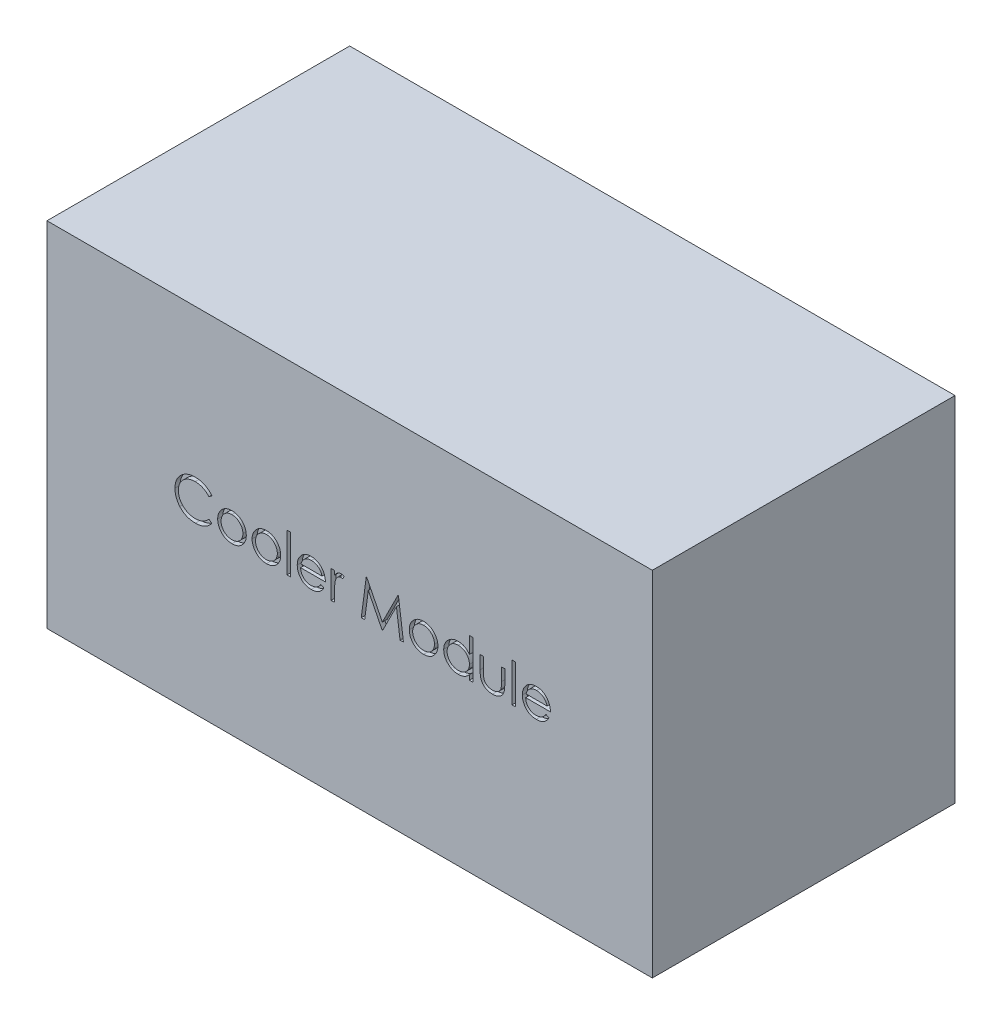
from build123d import *

# Parameters (mm, degrees)
SKETCH1_W           = 304.8
SKETCH1_H           = 177.8
BOSS_EXTRUDE1_DEPTH = 76.2
SKETCH2_W           = 1.709615385
SKETCH2_H           = 19.538461538
CUT_EXTRUDE1_DEPTH  = 2.54


with BuildPart() as part:
    # Sketch1 → Boss-Extrude1 (new body, symmetric)
    with BuildSketch(Plane.XY):
        Rectangle(SKETCH1_W, SKETCH1_H)
    extrude(amount=BOSS_EXTRUDE1_DEPTH, both=True)

    # Sketch2 → Cut-Extrude1 (cut)
    with BuildSketch(Plane.XY.offset(76.2)):
        with BuildLine():
            Line((-69.387672667, 10.444990481), (-70.883586129, 9.30015875))
            add(Edge.make_bspline(
                [(-70.883586129, 9.30015875), (-70.990298178, 9.427336386), (-71.202283568, 9.679977027), (-71.543328656, 10.034739977), (-71.898756169, 10.367109471), (-72.268430243, 10.678668844), (-72.659004879, 10.958522955), (-73.061018655, 11.221255672), (-73.481196587, 11.456755789), (-74.062231028, 11.742304328), (-74.822314316, 12.040279828), (-75.779140512, 12.290124559), (-76.777965205, 12.449171244), (-77.459397855, 12.466397024), (-77.806001994, 12.47515875)],
                knots=[0, 0, 0, 0, 0.00049794, 0.000989166, 0.001475147, 0.001957397, 0.002438287, 0.002915667, 0.003397525, 0.003882215, 0.004857325, 0.005840349, 0.006844209, 0.007883375, 0.007883375, 0.007883375, 0.007883375], degree=3))
            add(Edge.make_bspline(
                [(-77.806001994, 12.47515875), (-77.996955381, 12.47296004), (-78.377089926, 12.468583026), (-78.94123376, 12.410839073), (-79.494843367, 12.329679487), (-80.037558633, 12.209254513), (-80.568688736, 12.057003544), (-81.091705953, 11.875073791), (-81.599037932, 11.649985305), (-82.097702914, 11.401201776), (-82.57547262, 11.12020097), (-83.02752938, 10.81369544), (-83.452224463, 10.485115072), (-83.849893823, 10.133228336), (-84.220943999, 9.759619951), (-84.562686362, 9.360308321), (-84.873938381, 8.936570062), (-85.160869617, 8.493992801), (-85.41784178, 8.033865678), (-85.632997266, 7.554485651), (-85.823525146, 7.064061891), (-85.974288167, 6.55705343), (-86.09362018, 6.037027804), (-86.17595789, 5.502589373), (-86.23304514, 4.954854631), (-86.237400389, 4.583601086), (-86.239595744, 4.396462837)],
                knots=[0, 0, 0, 0, 0.000572619, 0.001139924, 0.001699592, 0.002250514, 0.002806148, 0.003356514, 0.003910218, 0.00446999, 0.005027612, 0.005571644, 0.006107491, 0.006637367, 0.007163561, 0.007685922, 0.008212558, 0.008739692, 0.009267502, 0.009791769, 0.010314798, 0.010844798, 0.0113771, 0.011914141, 0.012466252, 0.013027427, 0.013027427, 0.013027427, 0.013027427], degree=3))
            add(Edge.make_bspline(
                [(-86.239595744, 4.396462837), (-86.232727844, 4.114896653), (-86.219243632, 3.562078798), (-86.099237699, 2.752341618), (-85.916874274, 1.97662195), (-85.643558062, 1.239768809), (-85.306541515, 0.532696174), (-84.880689044, -0.132632442), (-84.387476176, -0.766271172), (-83.819925408, -1.35324493), (-83.197230895, -1.889441064), (-82.529131548, -2.361612086), (-81.817291353, -2.755211661), (-81.06956998, -3.082740741), (-80.28021356, -3.334509501), (-79.450641564, -3.511751374), (-78.582658275, -3.627369528), (-77.989553399, -3.638438601), (-77.687702715, -3.644072019)],
                knots=[0, 0, 0, 0, 0.000844222, 0.001657519, 0.002450727, 0.003230596, 0.004010586, 0.004796148, 0.005595401, 0.006415872, 0.007241219, 0.008057492, 0.008865515, 0.009677279, 0.010502758, 0.011346325, 0.012219621, 0.01312469, 0.01312469, 0.01312469, 0.01312469], degree=3))
            add(Edge.make_bspline(
                [(-77.687702715, -3.644072019), (-77.355129508, -3.634880232), (-76.700545878, -3.616788596), (-75.740599906, -3.463521826), (-74.821650953, -3.215012302), (-73.94364959, -2.867225039), (-73.109071015, -2.415112544), (-72.316609193, -1.867028382), (-71.565595216, -1.217759028), (-71.11399438, -0.722006573), (-70.883586129, -0.469072019)],
                knots=[0, 0, 0, 0, 0.000997238, 0.001962804, 0.002907981, 0.00384834, 0.004789132, 0.005749229, 0.006733947, 0.007759692, 0.007759692, 0.007759692, 0.007759692], degree=3))
            Line((-70.883586129, -0.469072019), (-69.387672667, -1.602455432))
            add(Edge.make_bspline(
                [(-69.387672667, -1.602455432), (-69.50805838, -1.757786149), (-69.748253164, -2.067703558), (-70.137188942, -2.504611006), (-70.546912518, -2.915568685), (-70.980467168, -3.297263309), (-71.432865434, -3.657332615), (-71.912230448, -3.985546868), (-72.412260468, -4.286487253), (-72.931261274, -4.56204237), (-73.468681438, -4.806520529), (-74.023877006, -5.015818894), (-74.594454852, -5.196112935), (-75.180441062, -5.344441334), (-75.78305111, -5.460216805), (-76.400110405, -5.537612463), (-77.032950726, -5.590636312), (-77.459896175, -5.595469111), (-77.676254398, -5.597918173)],
                knots=[0, 0, 0, 0, 0.000589425, 0.001176026, 0.001753482, 0.00232931, 0.002908013, 0.003487018, 0.004070795, 0.004658029, 0.005248935, 0.005840739, 0.006436956, 0.007043188, 0.007653157, 0.008276538, 0.008908147, 0.009557065, 0.009557065, 0.009557065, 0.009557065], degree=3))
            add(Edge.make_bspline(
                [(-77.676254398, -5.597918173), (-77.8811435, -5.596492185), (-78.286286328, -5.59367247), (-78.884449533, -5.547995102), (-79.466778537, -5.485675819), (-80.031609001, -5.391840249), (-80.582023236, -5.281108912), (-81.113031561, -5.132675358), (-81.629859205, -4.966400609), (-82.130429746, -4.770974895), (-82.615168969, -4.550451102), (-83.082513428, -4.301214188), (-83.532248181, -4.025360039), (-83.968794829, -3.728969197), (-84.385704534, -3.402521311), (-84.786590151, -3.050550057), (-85.173699629, -2.674241742), (-85.413199957, -2.402888897), (-85.533616177, -2.266457836)],
                knots=[0, 0, 0, 0, 0.0006145, 0.001215097, 0.001798762, 0.002370923, 0.002932241, 0.003482144, 0.004023991, 0.004560449, 0.005093244, 0.005620764, 0.006148271, 0.006675391, 0.00720287, 0.00773561, 0.008275316, 0.008821059, 0.008821059, 0.008821059, 0.008821059], degree=3))
            add(Edge.make_bspline(
                [(-85.533616177, -2.266457836), (-85.726487322, -2.029469365), (-86.109901103, -1.558353556), (-86.600442324, -0.794797001), (-87.020345446, 0.002408536), (-87.359848672, 0.837451292), (-87.625257262, 1.708457499), (-87.809123481, 2.615866228), (-87.928602928, 3.558830027), (-87.942266072, 4.200198834), (-87.949211129, 4.526210433)],
                knots=[0, 0, 0, 0, 0.000916064, 0.001821069, 0.002717204, 0.003615773, 0.004521164, 0.005444709, 0.006390426, 0.007368094, 0.007368094, 0.007368094, 0.007368094], degree=3))
            add(Edge.make_bspline(
                [(-87.949211129, 4.526210433), (-87.940746433, 4.868867973), (-87.924092671, 5.543025291), (-87.78260127, 6.532394951), (-87.554987536, 7.480276136), (-87.231698757, 8.384899375), (-86.821822488, 9.251022757), (-86.315491918, 10.072029886), (-85.71858933, 10.853171324), (-85.03579614, 11.582594471), (-84.287036786, 12.249558661), (-83.485201528, 12.836332428), (-82.631859788, 13.32465205), (-81.736412624, 13.732845449), (-80.792154843, 14.046596027), (-79.801101076, 14.266232657), (-78.765113555, 14.402941533), (-78.058290924, 14.420223736), (-77.699151033, 14.429004904)],
                knots=[0, 0, 0, 0, 0.001027553, 0.002021647, 0.002991636, 0.003947584, 0.004898354, 0.00586111, 0.006835779, 0.007842891, 0.008853835, 0.009840024, 0.01081793, 0.011798246, 0.012787788, 0.013796915, 0.014839669, 0.015916785, 0.015916785, 0.015916785, 0.015916785], degree=3))
            add(Edge.make_bspline(
                [(-77.699151033, 14.429004904), (-77.480269407, 14.426380695), (-77.047015272, 14.421186337), (-76.406104406, 14.370534335), (-75.782122598, 14.286095992), (-75.174639968, 14.171164241), (-74.580701156, 14.028521534), (-74.00484556, 13.842700767), (-73.443694135, 13.630230504), (-72.900785964, 13.385527997), (-72.378725884, 13.110844733), (-71.877676493, 12.80922541), (-71.401617762, 12.481043955), (-70.947199887, 12.129091528), (-70.52202451, 11.745922227), (-70.114019891, 11.342075312), (-69.737041737, 10.905918355), (-69.504342204, 10.598914357), (-69.387672667, 10.444990481)],
                knots=[0, 0, 0, 0, 0.000656548, 0.00129957, 0.001927235, 0.002544702, 0.003153715, 0.00375836, 0.004358654, 0.004953036, 0.005543646, 0.006127422, 0.006706428, 0.007277417, 0.007850392, 0.008422452, 0.008998633, 0.009577991, 0.009577991, 0.009577991, 0.009577991], degree=3))
        make_face()
        with BuildLine():
            add(Edge.make_bspline(
                [(-59.244463533, 9.055927981), (-58.983253891, 9.050365974), (-58.471085619, 9.039460236), (-57.721016983, 8.922901637), (-57.0050356, 8.744662411), (-56.320399325, 8.498255766), (-55.675876346, 8.167972578), (-55.062078574, 7.773859151), (-54.480688855, 7.306956749), (-54.132220653, 6.945779262), (-53.955340937, 6.762448414)],
                knots=[0, 0, 0, 0, 0.000783055, 0.00153538, 0.002271186, 0.002994326, 0.003712818, 0.004438972, 0.005179778, 0.005943429, 0.005943429, 0.005943429, 0.005943429], degree=3))
            add(Edge.make_bspline(
                [(-53.955340937, 6.762448414), (-53.803039158, 6.587112291), (-53.50138306, 6.239833283), (-53.114582505, 5.676739161), (-52.781362299, 5.093590899), (-52.514319611, 4.482644735), (-52.303762554, 3.849234025), (-52.154270693, 3.19118165), (-52.06535109, 2.509940875), (-52.053360655, 2.047277128), (-52.047288052, 1.812959231)],
                knots=[0, 0, 0, 0, 0.000696259, 0.001379043, 0.002045498, 0.002708457, 0.003375796, 0.004045107, 0.00473002, 0.005432847, 0.005432847, 0.005432847, 0.005432847], degree=3))
            add(Edge.make_bspline(
                [(-52.047288052, 1.812959231), (-52.052629331, 1.577283203), (-52.063183947, 1.11157638), (-52.16302563, 0.425670975), (-52.318316255, -0.239417989), (-52.540558117, -0.880906022), (-52.825535826, -1.500753982), (-53.173283711, -2.096254529), (-53.586242084, -2.668582569), (-54.054349553, -3.212878289), (-54.571703336, -3.714525829), (-55.1329498, -4.151741125), (-55.727059612, -4.52632685), (-56.361932721, -4.828059341), (-57.031771471, -5.065964996), (-57.738020656, -5.233060799), (-58.47958311, -5.334089392), (-58.985916986, -5.347062841), (-59.244463533, -5.353687404)],
                knots=[0, 0, 0, 0, 0.000706639, 0.001396352, 0.002074825, 0.002753062, 0.003429246, 0.004118441, 0.004818465, 0.005543646, 0.006269639, 0.006976516, 0.007674289, 0.008372397, 0.009080888, 0.009802849, 0.01054601, 0.011321441, 0.011321441, 0.011321441, 0.011321441], degree=3))
            add(Edge.make_bspline(
                [(-59.244463533, -5.353687404), (-59.504276792, -5.347040607), (-60.013134185, -5.33402252), (-60.757314173, -5.23345331), (-61.464829099, -5.066042005), (-62.135544756, -4.827277509), (-62.773147423, -4.526317206), (-63.370699642, -4.152873581), (-63.93240204, -3.714396165), (-64.449865269, -3.212913422), (-64.917943393, -2.668573517), (-65.330909338, -2.096256879), (-65.678655256, -1.50075337), (-65.96363348, -0.880906185), (-66.185875205, -0.239417945), (-66.341165866, 0.425670963), (-66.44100754, 1.111576383), (-66.451562157, 1.577283204), (-66.456903437, 1.812959231)],
                knots=[0, 0, 0, 0, 0.000779243, 0.001526186, 0.002248147, 0.002956639, 0.00365819, 0.004359201, 0.005066078, 0.005792071, 0.006517252, 0.007217276, 0.007906471, 0.008582655, 0.009260891, 0.009939365, 0.010629078, 0.011335717, 0.011335717, 0.011335717, 0.011335717], degree=3))
            add(Edge.make_bspline(
                [(-66.456903437, 1.812959231), (-66.450789419, 2.046003574), (-66.438684714, 2.507391321), (-66.349854515, 3.187351466), (-66.2009458, 3.844290112), (-65.990136343, 4.475255917), (-65.720632232, 5.08352479), (-65.392094365, 5.668113942), (-65.001348208, 6.228661827), (-64.700891872, 6.575492005), (-64.548850552, 6.751000096)],
                knots=[0, 0, 0, 0, 0.000699014, 0.001383928, 0.002053239, 0.002716956, 0.003376425, 0.004046203, 0.004725856, 0.005422115, 0.005422115, 0.005422115, 0.005422115], degree=3))
            add(Edge.make_bspline(
                [(-64.548850552, 6.751000096), (-64.372237507, 6.935920837), (-64.024896876, 7.299600012), (-63.440613087, 7.765141322), (-62.828325289, 8.167455953), (-62.17667962, 8.491176497), (-61.492605778, 8.746111857), (-60.77295533, 8.923361304), (-60.020341453, 9.039040279), (-59.505666944, 9.050242647), (-59.244463533, 9.055927981)],
                knots=[0, 0, 0, 0, 0.000766344, 0.00150715, 0.002235377, 0.002960688, 0.003685145, 0.004420951, 0.005180826, 0.005963881, 0.005963881, 0.005963881, 0.005963881], degree=3))
        make_face()
        with BuildLine():
            add(Edge.make_bspline(
                [(-59.252095744, 7.346312596), (-59.436813315, 7.341062462), (-59.801480001, 7.330697724), (-60.338252312, 7.2518639), (-60.854998007, 7.126963913), (-61.352697458, 6.949504693), (-61.829672297, 6.7203664), (-62.286379187, 6.438925182), (-62.724161467, 6.108908662), (-63.134455269, 5.730833264), (-63.511004711, 5.317834736), (-63.840177698, 4.877788669), (-64.120077205, 4.417832698), (-64.35325007, 3.93748852), (-64.526916337, 3.431888382), (-64.653043788, 2.906758089), (-64.73180324, 2.361027751), (-64.742070529, 1.990037065), (-64.747288052, 1.801510914)],
                knots=[0, 0, 0, 0, 0.00055398, 0.001093659, 0.001624001, 0.002146641, 0.00267576, 0.003208513, 0.003753455, 0.004317942, 0.004879857, 0.00542785, 0.00596386, 0.006492979, 0.007026416, 0.007564175, 0.008111411, 0.008676826, 0.008676826, 0.008676826, 0.008676826], degree=3))
            add(Edge.make_bspline(
                [(-64.747288052, 1.801510914), (-64.738542341, 1.557932023), (-64.721183739, 1.074473473), (-64.580021952, 0.36248722), (-64.343876628, -0.321036861), (-64.024994435, -0.972091762), (-63.625454873, -1.574465161), (-63.154718124, -2.111519955), (-62.617836327, -2.575174157), (-62.021209375, -2.959879902), (-61.377023731, -3.265549429), (-60.695271469, -3.482169569), (-59.984212834, -3.622985494), (-59.498270569, -3.636981662), (-59.252095744, -3.644072019)],
                knots=[0, 0, 0, 0, 0.000730313, 0.001449535, 0.002167582, 0.002894618, 0.003618562, 0.004329721, 0.005030483, 0.005739673, 0.006453204, 0.007162815, 0.007881317, 0.008619021, 0.008619021, 0.008619021, 0.008619021], degree=3))
            add(Edge.make_bspline(
                [(-59.252095744, -3.644072019), (-59.005935079, -3.636940351), (-58.520020764, -3.622862635), (-57.809950101, -3.482878774), (-57.130061197, -3.264600278), (-56.486544645, -2.960223678), (-55.890189275, -2.573713249), (-55.349446201, -2.114138111), (-54.88272876, -1.57304272), (-54.483584425, -0.971293885), (-54.159480011, -0.322046197), (-53.924440012, 0.362613374), (-53.782938866, 1.074441345), (-53.76562607, 1.557921259), (-53.756903437, 1.801510914)],
                knots=[0, 0, 0, 0, 0.000737704, 0.001456207, 0.002162186, 0.002875716, 0.003584906, 0.004288562, 0.004997207, 0.005721152, 0.006449878, 0.007167925, 0.007887147, 0.00861746, 0.00861746, 0.00861746, 0.00861746], degree=3))
            add(Edge.make_bspline(
                [(-53.756903437, 1.801510914), (-53.762119164, 1.990038192), (-53.772382918, 2.361031095), (-53.851168081, 2.906745306), (-53.977200375, 3.431935282), (-54.151217321, 3.937315472), (-54.383377025, 4.419076388), (-54.668674141, 4.876438188), (-54.996503008, 5.319359103), (-55.377596195, 5.729498205), (-55.787461723, 6.109056047), (-56.225421431, 6.439053152), (-56.6814511, 6.719129493), (-57.157040243, 6.951464603), (-57.654803504, 7.125349412), (-58.170825164, 7.252585078), (-58.705307258, 7.330364577), (-59.068667193, 7.34096259), (-59.252095744, 7.346312596)],
                knots=[0, 0, 0, 0, 0.000565415, 0.00111265, 0.00165041, 0.002183846, 0.002712966, 0.003250969, 0.003798962, 0.004363449, 0.004927936, 0.005472878, 0.006005632, 0.006531314, 0.007057549, 0.007584185, 0.008123864, 0.008674032, 0.008674032, 0.008674032, 0.008674032], degree=3))
        make_face(mode=Mode.SUBTRACT)
        with BuildLine():
            add(Edge.make_bspline(
                [(-41.904078917, 9.055927981), (-41.642869275, 9.050365974), (-41.130701003, 9.039460236), (-40.380632367, 8.922901637), (-39.664650985, 8.744662411), (-38.98001471, 8.498255766), (-38.335491731, 8.167972578), (-37.721693959, 7.773859151), (-37.140304239, 7.306956749), (-36.791836037, 6.945779262), (-36.614956321, 6.762448414)],
                knots=[0, 0, 0, 0, 0.000783055, 0.00153538, 0.002271186, 0.002994326, 0.003712818, 0.004438972, 0.005179778, 0.005943429, 0.005943429, 0.005943429, 0.005943429], degree=3))
            add(Edge.make_bspline(
                [(-36.614956321, 6.762448414), (-36.462654543, 6.587112291), (-36.160998445, 6.239833283), (-35.774197889, 5.676739161), (-35.440977683, 5.093590899), (-35.173934996, 4.482644735), (-34.963377938, 3.849234025), (-34.813886077, 3.19118165), (-34.724966474, 2.509940875), (-34.71297604, 2.047277128), (-34.706903437, 1.812959231)],
                knots=[0, 0, 0, 0, 0.000696259, 0.001379043, 0.002045498, 0.002708457, 0.003375796, 0.004045107, 0.00473002, 0.005432847, 0.005432847, 0.005432847, 0.005432847], degree=3))
            add(Edge.make_bspline(
                [(-34.706903437, 1.812959231), (-34.712244715, 1.577283203), (-34.722799332, 1.11157638), (-34.822641015, 0.425670975), (-34.97793164, -0.239417989), (-35.200173502, -0.880906022), (-35.485151211, -1.500753982), (-35.832899096, -2.096254529), (-36.245857469, -2.668582569), (-36.713964937, -3.212878289), (-37.23131872, -3.714525829), (-37.792565185, -4.151741125), (-38.386674997, -4.52632685), (-39.021548105, -4.828059341), (-39.691386855, -5.065964996), (-40.39763604, -5.233060799), (-41.139198494, -5.334089392), (-41.645532371, -5.347062841), (-41.904078917, -5.353687404)],
                knots=[0, 0, 0, 0, 0.000706639, 0.001396352, 0.002074825, 0.002753062, 0.003429246, 0.004118441, 0.004818465, 0.005543646, 0.006269639, 0.006976516, 0.007674289, 0.008372397, 0.009080888, 0.009802849, 0.01054601, 0.011321441, 0.011321441, 0.011321441, 0.011321441], degree=3))
            add(Edge.make_bspline(
                [(-41.904078917, -5.353687404), (-42.163892176, -5.347040607), (-42.67274957, -5.33402252), (-43.416929557, -5.23345331), (-44.124444483, -5.066042005), (-44.795160141, -4.827277509), (-45.432762808, -4.526317206), (-46.030315027, -4.152873581), (-46.592017424, -3.714396165), (-47.109480654, -3.212913422), (-47.577558777, -2.668573517), (-47.990524723, -2.096256879), (-48.338270641, -1.50075337), (-48.623248865, -0.880906185), (-48.845490589, -0.239417945), (-49.000781251, 0.425670963), (-49.100622924, 1.111576383), (-49.111177542, 1.577283204), (-49.116518821, 1.812959231)],
                knots=[0, 0, 0, 0, 0.000779243, 0.001526186, 0.002248147, 0.002956639, 0.00365819, 0.004359201, 0.005066078, 0.005792071, 0.006517252, 0.007217276, 0.007906471, 0.008582655, 0.009260891, 0.009939365, 0.010629078, 0.011335717, 0.011335717, 0.011335717, 0.011335717], degree=3))
            add(Edge.make_bspline(
                [(-49.116518821, 1.812959231), (-49.110404803, 2.046003574), (-49.098300099, 2.507391321), (-49.0094699, 3.187351466), (-48.860561185, 3.844290112), (-48.649751727, 4.475255917), (-48.380247617, 5.08352479), (-48.05170975, 5.668113942), (-47.660963592, 6.228661827), (-47.360507256, 6.575492005), (-47.208465937, 6.751000096)],
                knots=[0, 0, 0, 0, 0.000699014, 0.001383928, 0.002053239, 0.002716956, 0.003376425, 0.004046203, 0.004725856, 0.005422115, 0.005422115, 0.005422115, 0.005422115], degree=3))
            add(Edge.make_bspline(
                [(-47.208465937, 6.751000096), (-47.031852891, 6.935920837), (-46.684512261, 7.299600012), (-46.100228471, 7.765141322), (-45.487940674, 8.167455953), (-44.836295004, 8.491176497), (-44.152221163, 8.746111857), (-43.432570714, 8.923361304), (-42.679956837, 9.039040279), (-42.165282328, 9.050242647), (-41.904078917, 9.055927981)],
                knots=[0, 0, 0, 0, 0.000766344, 0.00150715, 0.002235377, 0.002960688, 0.003685145, 0.004420951, 0.005180826, 0.005963881, 0.005963881, 0.005963881, 0.005963881], degree=3))
        make_face()
        with BuildLine():
            add(Edge.make_bspline(
                [(-41.911711129, 7.346312596), (-42.096428699, 7.341062462), (-42.461095385, 7.330697724), (-42.997867696, 7.2518639), (-43.514613391, 7.126963913), (-44.012312843, 6.949504693), (-44.489287681, 6.7203664), (-44.945994572, 6.438925182), (-45.383776852, 6.108908662), (-45.794070654, 5.730833264), (-46.170620095, 5.317834736), (-46.499793082, 4.877788669), (-46.77969259, 4.417832698), (-47.012865455, 3.93748852), (-47.186531722, 3.431888382), (-47.312659173, 2.906758089), (-47.391418624, 2.361027751), (-47.401685913, 1.990037065), (-47.406903437, 1.801510914)],
                knots=[0, 0, 0, 0, 0.00055398, 0.001093659, 0.001624001, 0.002146641, 0.00267576, 0.003208513, 0.003753455, 0.004317942, 0.004879857, 0.00542785, 0.00596386, 0.006492979, 0.007026416, 0.007564175, 0.008111411, 0.008676826, 0.008676826, 0.008676826, 0.008676826], degree=3))
            add(Edge.make_bspline(
                [(-47.406903437, 1.801510914), (-47.398157725, 1.557932023), (-47.380799123, 1.074473473), (-47.239637336, 0.36248722), (-47.003492013, -0.321036861), (-46.684609819, -0.972091762), (-46.285070257, -1.574465161), (-45.814333509, -2.111519955), (-45.277451711, -2.575174157), (-44.68082476, -2.959879902), (-44.036639115, -3.265549429), (-43.354886853, -3.482169569), (-42.643828219, -3.622985494), (-42.157885953, -3.636981662), (-41.911711129, -3.644072019)],
                knots=[0, 0, 0, 0, 0.000730313, 0.001449535, 0.002167582, 0.002894618, 0.003618562, 0.004329721, 0.005030483, 0.005739673, 0.006453204, 0.007162815, 0.007881317, 0.008619021, 0.008619021, 0.008619021, 0.008619021], degree=3))
            add(Edge.make_bspline(
                [(-41.911711129, -3.644072019), (-41.665550464, -3.636940351), (-41.179636149, -3.622862635), (-40.469565486, -3.482878774), (-39.789676582, -3.264600278), (-39.14616003, -2.960223678), (-38.54980466, -2.573713249), (-38.009061585, -2.114138111), (-37.542344145, -1.57304272), (-37.143199809, -0.971293885), (-36.819095395, -0.322046197), (-36.584055397, 0.362613374), (-36.442554251, 1.074441345), (-36.425241455, 1.557921259), (-36.416518821, 1.801510914)],
                knots=[0, 0, 0, 0, 0.000737704, 0.001456207, 0.002162186, 0.002875716, 0.003584906, 0.004288562, 0.004997207, 0.005721152, 0.006449878, 0.007167925, 0.007887147, 0.00861746, 0.00861746, 0.00861746, 0.00861746], degree=3))
            add(Edge.make_bspline(
                [(-36.416518821, 1.801510914), (-36.421734548, 1.990038192), (-36.431998302, 2.361031095), (-36.510783466, 2.906745306), (-36.63681576, 3.431935282), (-36.810832705, 3.937315472), (-37.042992409, 4.419076388), (-37.328289526, 4.876438188), (-37.656118393, 5.319359103), (-38.037211579, 5.729498205), (-38.447077108, 6.109056047), (-38.885036815, 6.439053152), (-39.341066485, 6.719129493), (-39.816655627, 6.951464603), (-40.314418888, 7.125349412), (-40.830440549, 7.252585078), (-41.364922643, 7.330364577), (-41.728282578, 7.34096259), (-41.911711129, 7.346312596)],
                knots=[0, 0, 0, 0, 0.000565415, 0.00111265, 0.00165041, 0.002183846, 0.002712966, 0.003250969, 0.003798962, 0.004363449, 0.004927936, 0.005472878, 0.006005632, 0.006531314, 0.007057549, 0.007584185, 0.008123864, 0.008674032, 0.008674032, 0.008674032, 0.008674032], degree=3))
        make_face(mode=Mode.SUBTRACT)
        with Locations((-30.677095745, 4.659774135)):
            Rectangle(SKETCH2_W, SKETCH2_H)
        with BuildLine():
            Line((-14.489175071, -0.713302788), (-12.970364975, -1.510868894))
            add(Edge.make_bspline(
                [(-12.970364975, -1.510868894), (-13.091395586, -1.725553311), (-13.326873227, -2.143244171), (-13.731825869, -2.717094726), (-14.156325578, -3.233337293), (-14.619534318, -3.678180126), (-15.107593571, -4.065991236), (-15.623209878, -4.40528711), (-16.169067586, -4.694403628), (-16.745192516, -4.937985244), (-17.35642293, -5.125271205), (-18.004240041, -5.257555607), (-18.689884894, -5.339325112), (-19.159854816, -5.348823664), (-19.400503196, -5.353687404)],
                knots=[0, 0, 0, 0, 0.000738917, 0.001437639, 0.002104094, 0.002741006, 0.003360227, 0.003971996, 0.004589981, 0.005210834, 0.005845755, 0.006504362, 0.00719213, 0.007913868, 0.007913868, 0.007913868, 0.007913868], degree=3))
            add(Edge.make_bspline(
                [(-19.400503196, -5.353687404), (-19.66797596, -5.347443492), (-20.189737834, -5.33526343), (-20.949232743, -5.230257302), (-21.664312149, -5.05895775), (-22.334935849, -4.819659588), (-22.959461538, -4.507090867), (-23.539130476, -4.126311402), (-24.076991038, -3.679277273), (-24.556094234, -3.162116344), (-24.987407367, -2.608675977), (-25.368003616, -2.031973234), (-25.686179062, -1.433459112), (-25.945001126, -0.816943832), (-26.15403332, -0.186313211), (-26.299720664, 0.464170634), (-26.383702578, 1.132747171), (-26.396571918, 1.585034098), (-26.403057283, 1.812959231)],
                knots=[0, 0, 0, 0, 0.000802118, 0.0015647, 0.002294973, 0.003004748, 0.003695927, 0.004384964, 0.005081223, 0.005788532, 0.006495408, 0.007184445, 0.007858774, 0.008525719, 0.00918824, 0.009849264, 0.010522339, 0.011206103, 0.011206103, 0.011206103, 0.011206103], degree=3))
            add(Edge.make_bspline(
                [(-26.403057283, 1.812959231), (-26.397292528, 2.026835379), (-26.385867545, 2.450709662), (-26.313854259, 3.078083554), (-26.18622855, 3.687838417), (-26.011097415, 4.280480912), (-25.784939918, 4.855018756), (-25.508267411, 5.411801616), (-25.180648897, 5.950237021), (-24.927704773, 6.289888363), (-24.80029286, 6.460976058)],
                knots=[0, 0, 0, 0, 0.000641662, 0.001271689, 0.001891381, 0.002508376, 0.003123479, 0.003741276, 0.004371535, 0.00501123, 0.00501123, 0.00501123, 0.00501123], degree=3))
            add(Edge.make_bspline(
                [(-24.80029286, 6.460976058), (-24.627712472, 6.667090908), (-24.288018606, 7.072791413), (-23.713490443, 7.605855729), (-23.091370803, 8.052408276), (-22.429456095, 8.422561403), (-21.720053286, 8.703813682), (-20.972698431, 8.913404951), (-20.17888174, 9.030850982), (-19.636200466, 9.047439905), (-19.358526033, 9.055927981)],
                knots=[0, 0, 0, 0, 0.00080593, 0.001586331, 0.002343585, 0.003098605, 0.003855427, 0.004627573, 0.005422542, 0.006255512, 0.006255512, 0.006255512, 0.006255512], degree=3))
            add(Edge.make_bspline(
                [(-19.358526033, 9.055927981), (-19.07306121, 9.048558086), (-18.5130443, 9.034100033), (-17.696440898, 8.900062418), (-16.923768998, 8.687504943), (-16.195337796, 8.38731074), (-15.51107344, 7.999999465), (-14.875423655, 7.520256014), (-14.277517566, 6.962808996), (-13.929672301, 6.534112099), (-13.752666658, 6.315964039)],
                knots=[0, 0, 0, 0, 0.000855838, 0.001678959, 0.002475209, 0.00325546, 0.004036458, 0.004827156, 0.005639736, 0.006481644, 0.006481644, 0.006481644, 0.006481644], degree=3))
            add(Edge.make_bspline(
                [(-13.752666658, 6.315964039), (-13.632232894, 6.15157026), (-13.392167008, 5.823876957), (-13.091464935, 5.289545373), (-12.830439685, 4.730506281), (-12.621798855, 4.137723093), (-12.452855284, 3.518219378), (-12.330626028, 2.867566384), (-12.258945675, 2.185957867), (-12.244855765, 1.721537615), (-12.237672667, 1.484774135)],
                knots=[0, 0, 0, 0, 0.000610875, 0.001217684, 0.001835763, 0.002459799, 0.003100405, 0.003760536, 0.004443661, 0.005154113, 0.005154113, 0.005154113, 0.005154113], degree=3))
            Line((-12.237672667, 1.484774135), (-24.693441898, 1.484774135))
            add(Edge.make_bspline(
                [(-24.693441898, 1.484774135), (-24.68506204, 1.301347322), (-24.668583388, 0.940645893), (-24.59175668, 0.412847774), (-24.470659783, -0.089927131), (-24.300466742, -0.563907688), (-24.094362913, -1.015284525), (-23.841892083, -1.440709326), (-23.540686796, -1.838244346), (-23.204722632, -2.21144548), (-22.830759728, -2.54379048), (-22.437335061, -2.841252291), (-22.018814371, -3.09056561), (-21.57849766, -3.292930439), (-21.117096943, -3.451351959), (-20.634466853, -3.559489669), (-20.131557105, -3.63191835), (-19.788734753, -3.639971957), (-19.614205119, -3.644072019)],
                knots=[0, 0, 0, 0, 0.000550591, 0.001082716, 0.001597325, 0.002099429, 0.002591174, 0.003083984, 0.003580077, 0.004085261, 0.004587887, 0.005078639, 0.005562939, 0.006046155, 0.006530079, 0.007023479, 0.007528086, 0.008051394, 0.008051394, 0.008051394, 0.008051394], degree=3))
            add(Edge.make_bspline(
                [(-19.614205119, -3.644072019), (-19.443565302, -3.640762453), (-19.10498317, -3.634195641), (-18.600752218, -3.570340525), (-18.10469279, -3.467088025), (-17.618858009, -3.326172508), (-17.15310812, -3.154304213), (-16.721785911, -2.946915802), (-16.325109309, -2.717500752), (-15.954358391, -2.455102378), (-15.594743413, -2.133929245), (-15.238005023, -1.733140535), (-14.855499238, -1.259135563), (-14.616070169, -0.902379867), (-14.489175071, -0.713302788)],
                knots=[0, 0, 0, 0, 0.000511714, 0.001015339, 0.001522019, 0.002030479, 0.002531611, 0.003009539, 0.003464424, 0.003904933, 0.00436984, 0.00490737, 0.005512881, 0.006195665, 0.006195665, 0.006195665, 0.006195665], degree=3))
        make_face()
        with BuildLine():
            add(Edge.make_bspline(
                [(-13.947288052, 3.19438952), (-14.009862537, 3.421154589), (-14.130298278, 3.857604353), (-14.381956205, 4.461984056), (-14.665374162, 4.999128203), (-15.000772443, 5.46492592), (-15.380785792, 5.878602184), (-15.819726, 6.240109055), (-16.311955649, 6.563509753), (-16.854930401, 6.836482643), (-17.429923545, 7.068837445), (-18.031937247, 7.224639861), (-18.646206064, 7.331371798), (-19.06168268, 7.341311045), (-19.2707556, 7.346312596)],
                knots=[0, 0, 0, 0, 0.000705082, 0.001357055, 0.001959783, 0.002523172, 0.003074068, 0.003640358, 0.004224608, 0.004837304, 0.005460908, 0.006081104, 0.00669969, 0.007326276, 0.007326276, 0.007326276, 0.007326276], degree=3))
            add(Edge.make_bspline(
                [(-19.2707556, 7.346312596), (-19.441386115, 7.342983356), (-19.778686771, 7.336402146), (-20.275625442, 7.273971871), (-20.752853518, 7.170776144), (-21.213892297, 7.029452594), (-21.652700167, 6.841082915), (-22.078303119, 6.62019421), (-22.479879276, 6.350546447), (-22.731019756, 6.145030394), (-22.857895023, 6.041204423)],
                knots=[0, 0, 0, 0, 0.000511714, 0.001011551, 0.001499565, 0.001975126, 0.002455668, 0.002930217, 0.003411788, 0.003903473, 0.003903473, 0.003903473, 0.003903473], degree=3))
            add(Edge.make_bspline(
                [(-22.857895023, 6.041204423), (-22.948754172, 5.95904822), (-23.132630946, 5.792784087), (-23.378324355, 5.506330834), (-23.613567214, 5.197440188), (-23.827654667, 4.854294582), (-24.024019816, 4.480801484), (-24.207770549, 4.080111213), (-24.373159449, 3.649183175), (-24.466211133, 3.34888747), (-24.514084927, 3.19438952)],
                knots=[0, 0, 0, 0, 0.00036714, 0.000743003, 0.001129956, 0.001531229, 0.001954593, 0.002395167, 0.002852989, 0.003338129, 0.003338129, 0.003338129, 0.003338129], degree=3))
            Line((-24.514084927, 3.19438952), (-13.947288052, 3.19438952))
        make_face(mode=Mode.SUBTRACT)
        with BuildLine():
            Line((-9.306903437, 8.811697212), (-7.597288052, 8.811697212))
            Line((-7.597288052, 8.811697212), (-7.597288052, 6.762448414))
            add(Edge.make_bspline(
                [(-7.597288052, 6.762448414), (-7.471074951, 6.953252279), (-7.229693375, 7.31816319), (-6.828484431, 7.800777528), (-6.417530585, 8.200365139), (-5.994864495, 8.518791434), (-5.557377979, 8.757259981), (-5.114672571, 8.931937786), (-4.659783228, 9.035228601), (-4.354101897, 9.049018945), (-4.200953917, 9.055927981)],
                knots=[0, 0, 0, 0, 0.000685923, 0.001311823, 0.001878588, 0.00240216, 0.002894023, 0.003368834, 0.003826209, 0.004285428, 0.004285428, 0.004285428, 0.004285428], degree=3))
            add(Edge.make_bspline(
                [(-4.200953917, 9.055927981), (-4.08215634, 9.049448115), (-3.837722605, 9.036115369), (-3.467703081, 8.942439309), (-3.086466578, 8.792880358), (-2.840763013, 8.652235717), (-2.712672667, 8.57891476)],
                knots=[0, 0, 0, 0, 0.000356208, 0.000732922, 0.001138974, 0.001581198, 0.001581198, 0.001581198, 0.001581198], degree=3))
            Line((-2.712672667, 8.57891476), (-3.651434687, 7.098265721))
            add(Edge.make_bspline(
                [(-3.651434687, 7.098265721), (-3.73367093, 7.134952027), (-3.889771064, 7.204589658), (-4.118123774, 7.287005456), (-4.328660764, 7.335533512), (-4.462792132, 7.342885274), (-4.525322908, 7.346312596)],
                knots=[0, 0, 0, 0, 0.000270082, 0.000512668, 0.000727491, 0.000915102, 0.000915102, 0.000915102, 0.000915102], degree=3))
            add(Edge.make_bspline(
                [(-4.525322908, 7.346312596), (-4.662514114, 7.337168393), (-4.942344408, 7.318516869), (-5.353195755, 7.171892786), (-5.751869831, 6.934991122), (-6.068489879, 6.672258357), (-6.313648427, 6.418905345), (-6.488583083, 6.197661896), (-6.649053462, 5.949583916), (-6.802379948, 5.678912351), (-6.942077921, 5.381025618), (-7.072459763, 5.058899842), (-7.19034586, 4.712161927), (-7.257566475, 4.47059421), (-7.29199959, 4.346853462)],
                knots=[0, 0, 0, 0, 0.000410883, 0.000838083, 0.001292968, 0.001797214, 0.002067108, 0.002349602, 0.002641728, 0.002952711, 0.003282158, 0.003627974, 0.003994837, 0.004380112, 0.004380112, 0.004380112, 0.004380112], degree=3))
            add(Edge.make_bspline(
                [(-7.29199959, 4.346853462), (-7.317757332, 4.236487703), (-7.374808771, 3.992035933), (-7.430279855, 3.581924677), (-7.485086803, 3.09738162), (-7.523712683, 2.537058022), (-7.559516026, 1.902353148), (-7.579709474, 1.192300073), (-7.596599425, 0.406169976), (-7.597051546, -0.143419004), (-7.597288052, -0.430910961)],
                knots=[0, 0, 0, 0, 0.000339826, 0.000752689, 0.001240271, 0.001802807, 0.002437211, 0.003147375, 0.003933641, 0.00479609, 0.00479609, 0.00479609, 0.00479609], degree=3))
            Line((-7.597288052, -0.430910961), (-7.597288052, -5.109456634))
            Line((-7.597288052, -5.109456634), (-9.306903437, -5.109456634))
            Line((-9.306903437, -5.109456634), (-9.306903437, 8.811697212))
        make_face()
        Polygon((5.835404256, -5.109456634), (8.350217958, 13.940543366), (8.594448727, 13.940543366), (16.459442717, -1.690225865), (24.305356179, 13.940543366), (24.553403054, 13.940543366), (27.083481179, -5.109456634), (25.366233583, -5.109456634), (23.542135025, 8.597995289), (16.665512429, -5.109456634), (16.280085746, -5.109456634), (9.37675041, 8.628524135), (7.556467958, -5.109456634), align=None)
        with BuildLine():
            add(Edge.make_bspline(
                [(37.226690313, 9.055927981), (37.487899956, 9.050365974), (38.000068227, 9.039460236), (38.750136863, 8.922901637), (39.466118246, 8.744662411), (40.150754521, 8.498255766), (40.7952775, 8.167972578), (41.409075272, 7.773859151), (41.990464992, 7.306956749), (42.338933194, 6.945779262), (42.51581291, 6.762448414)],
                knots=[0, 0, 0, 0, 0.000783055, 0.00153538, 0.002271186, 0.002994326, 0.003712818, 0.004438972, 0.005179778, 0.005943429, 0.005943429, 0.005943429, 0.005943429], degree=3))
            add(Edge.make_bspline(
                [(42.51581291, 6.762448414), (42.668114688, 6.587112291), (42.969770786, 6.239833283), (43.356571341, 5.676739161), (43.689791547, 5.093590899), (43.956834235, 4.482644735), (44.167391292, 3.849234025), (44.316883154, 3.19118165), (44.405802757, 2.509940875), (44.417793191, 2.047277128), (44.423865794, 1.812959231)],
                knots=[0, 0, 0, 0, 0.000696259, 0.001379043, 0.002045498, 0.002708457, 0.003375796, 0.004045107, 0.00473002, 0.005432847, 0.005432847, 0.005432847, 0.005432847], degree=3))
            add(Edge.make_bspline(
                [(44.423865794, 1.812959231), (44.418524515, 1.577283203), (44.407969899, 1.11157638), (44.308128216, 0.425670975), (44.152837591, -0.239417989), (43.930595729, -0.880906022), (43.64561802, -1.500753982), (43.297870135, -2.096254529), (42.884911762, -2.668582569), (42.416804294, -3.212878289), (41.899450511, -3.714525829), (41.338204046, -4.151741125), (40.744094234, -4.52632685), (40.109221125, -4.828059341), (39.439382376, -5.065964996), (38.733133191, -5.233060799), (37.991570737, -5.334089392), (37.48523686, -5.347062841), (37.226690313, -5.353687404)],
                knots=[0, 0, 0, 0, 0.000706639, 0.001396352, 0.002074825, 0.002753062, 0.003429246, 0.004118441, 0.004818465, 0.005543646, 0.006269639, 0.006976516, 0.007674289, 0.008372397, 0.009080888, 0.009802849, 0.01054601, 0.011321441, 0.011321441, 0.011321441, 0.011321441], degree=3))
            add(Edge.make_bspline(
                [(37.226690313, -5.353687404), (36.966877054, -5.347040607), (36.458019661, -5.33402252), (35.713839673, -5.23345331), (35.006324747, -5.066042005), (34.33560909, -4.827277509), (33.698006423, -4.526317206), (33.100454204, -4.152873581), (32.538751806, -3.714396165), (32.021288577, -3.212913422), (31.553210454, -2.668573517), (31.140244508, -2.096256879), (30.79249859, -1.50075337), (30.507520366, -0.880906185), (30.285278642, -0.239417945), (30.12998798, 0.425670963), (30.030146306, 1.111576383), (30.019591689, 1.577283204), (30.01425041, 1.812959231)],
                knots=[0, 0, 0, 0, 0.000779243, 0.001526186, 0.002248147, 0.002956639, 0.00365819, 0.004359201, 0.005066078, 0.005792071, 0.006517252, 0.007217276, 0.007906471, 0.008582655, 0.009260891, 0.009939365, 0.010629078, 0.011335717, 0.011335717, 0.011335717, 0.011335717], degree=3))
            add(Edge.make_bspline(
                [(30.01425041, 1.812959231), (30.020364427, 2.046003574), (30.032469132, 2.507391321), (30.121299331, 3.187351466), (30.270208046, 3.844290112), (30.481017504, 4.475255917), (30.750521614, 5.08352479), (31.079059481, 5.668113942), (31.469805638, 6.228661827), (31.770261975, 6.575492005), (31.922303294, 6.751000096)],
                knots=[0, 0, 0, 0, 0.000699014, 0.001383928, 0.002053239, 0.002716956, 0.003376425, 0.004046203, 0.004725856, 0.005422115, 0.005422115, 0.005422115, 0.005422115], degree=3))
            add(Edge.make_bspline(
                [(31.922303294, 6.751000096), (32.09891634, 6.935920837), (32.44625697, 7.299600012), (33.030540759, 7.765141322), (33.642828557, 8.167455953), (34.294474227, 8.491176497), (34.978548068, 8.746111857), (35.698198516, 8.923361304), (36.450812393, 9.039040279), (36.965486902, 9.050242647), (37.226690313, 9.055927981)],
                knots=[0, 0, 0, 0, 0.000766344, 0.00150715, 0.002235377, 0.002960688, 0.003685145, 0.004420951, 0.005180826, 0.005963881, 0.005963881, 0.005963881, 0.005963881], degree=3))
        make_face()
        with BuildLine():
            add(Edge.make_bspline(
                [(37.219058102, 7.346312596), (37.034340532, 7.341062462), (36.669673846, 7.330697724), (36.132901535, 7.2518639), (35.61615584, 7.126963913), (35.118456388, 6.949504693), (34.641481549, 6.7203664), (34.184774659, 6.438925182), (33.746992379, 6.108908662), (33.336698577, 5.730833264), (32.960149135, 5.317834736), (32.630976148, 4.877788669), (32.351076641, 4.417832698), (32.117903776, 3.93748852), (31.944237509, 3.431888382), (31.818110058, 2.906758089), (31.739350607, 2.361027751), (31.729083317, 1.990037065), (31.723865794, 1.801510914)],
                knots=[0, 0, 0, 0, 0.00055398, 0.001093659, 0.001624001, 0.002146641, 0.00267576, 0.003208513, 0.003753455, 0.004317942, 0.004879857, 0.00542785, 0.00596386, 0.006492979, 0.007026416, 0.007564175, 0.008111411, 0.008676826, 0.008676826, 0.008676826, 0.008676826], degree=3))
            add(Edge.make_bspline(
                [(31.723865794, 1.801510914), (31.732611506, 1.557932023), (31.749970108, 1.074473473), (31.891131894, 0.36248722), (32.127277218, -0.321036861), (32.446159412, -0.972091762), (32.845698973, -1.574465161), (33.316435722, -2.111519955), (33.85331752, -2.575174157), (34.449944471, -2.959879902), (35.094130115, -3.265549429), (35.775882377, -3.482169569), (36.486941012, -3.622985494), (36.972883277, -3.636981662), (37.219058102, -3.644072019)],
                knots=[0, 0, 0, 0, 0.000730313, 0.001449535, 0.002167582, 0.002894618, 0.003618562, 0.004329721, 0.005030483, 0.005739673, 0.006453204, 0.007162815, 0.007881317, 0.008619021, 0.008619021, 0.008619021, 0.008619021], degree=3))
            add(Edge.make_bspline(
                [(37.219058102, -3.644072019), (37.465218767, -3.636940351), (37.951133082, -3.622862635), (38.661203745, -3.482878774), (39.341092649, -3.264600278), (39.984609201, -2.960223678), (40.580964571, -2.573713249), (41.121707646, -2.114138111), (41.588425086, -1.57304272), (41.987569421, -0.971293885), (42.311673835, -0.322046197), (42.546713834, 0.362613374), (42.68821498, 1.074441345), (42.705527776, 1.557921259), (42.71425041, 1.801510914)],
                knots=[0, 0, 0, 0, 0.000737704, 0.001456207, 0.002162186, 0.002875716, 0.003584906, 0.004288562, 0.004997207, 0.005721152, 0.006449878, 0.007167925, 0.007887147, 0.00861746, 0.00861746, 0.00861746, 0.00861746], degree=3))
            add(Edge.make_bspline(
                [(42.71425041, 1.801510914), (42.709034683, 1.990038192), (42.698770928, 2.361031095), (42.619985765, 2.906745306), (42.493953471, 3.431935282), (42.319936525, 3.937315472), (42.087776821, 4.419076388), (41.802479705, 4.876438188), (41.474650838, 5.319359103), (41.093557651, 5.729498205), (40.683692123, 6.109056047), (40.245732415, 6.439053152), (39.789702746, 6.719129493), (39.314113603, 6.951464603), (38.816350342, 7.125349412), (38.300328682, 7.252585078), (37.765846588, 7.330364577), (37.402486653, 7.34096259), (37.219058102, 7.346312596)],
                knots=[0, 0, 0, 0, 0.000565415, 0.00111265, 0.00165041, 0.002183846, 0.002712966, 0.003250969, 0.003798962, 0.004363449, 0.004927936, 0.005472878, 0.006005632, 0.006531314, 0.007057549, 0.007584185, 0.008123864, 0.008674032, 0.008674032, 0.008674032, 0.008674032], degree=3))
        make_face(mode=Mode.SUBTRACT)
        with BuildLine():
            Line((62.008481179, 14.429004904), (62.008481179, -5.109456634))
            Line((62.008481179, -5.109456634), (60.298865794, -5.109456634))
            Line((60.298865794, -5.109456634), (60.298865794, -2.701493894))
            add(Edge.make_bspline(
                [(60.298865794, -2.701493894), (60.106086377, -2.919423684), (59.729874919, -3.344716409), (59.101545406, -3.900335091), (58.435512894, -4.359594241), (57.735009989, -4.730524497), (57.000669265, -5.009155546), (56.234118561, -5.207200212), (55.435045188, -5.334529515), (54.889385943, -5.347244148), (54.612868198, -5.353687404)],
                knots=[0, 0, 0, 0, 0.000872287, 0.001702279, 0.002508878, 0.003294106, 0.004074404, 0.004859307, 0.005666168, 0.006495142, 0.006495142, 0.006495142, 0.006495142], degree=3))
            add(Edge.make_bspline(
                [(54.612868198, -5.353687404), (54.367025478, -5.347012434), (53.882212748, -5.3338491), (53.1690402, -5.231728562), (52.482738099, -5.067731892), (51.822657925, -4.839671337), (51.193070962, -4.537152865), (50.588586722, -4.174978358), (50.012336784, -3.74368184), (49.47310455, -3.250624142), (48.976541805, -2.715074284), (48.540779736, -2.143870664), (48.177452258, -1.539483267), (47.873631533, -0.909564244), (47.639608573, -0.249264468), (47.476466364, 0.439132689), (47.374464789, 1.154813287), (47.361306896, 1.64216412), (47.354635025, 1.889281346)],
                knots=[0, 0, 0, 0, 0.000737309, 0.001454006, 0.002156521, 0.002851681, 0.003544701, 0.004248243, 0.004962619, 0.005700116, 0.006437375, 0.007150997, 0.007851271, 0.008549378, 0.009245804, 0.00994832, 0.010668797, 0.011409917, 0.011409917, 0.011409917, 0.011409917], degree=3))
            add(Edge.make_bspline(
                [(47.354635025, 1.889281346), (47.361454769, 2.131290933), (47.374937036, 2.60973083), (47.475375275, 3.313376315), (47.644272622, 3.99111142), (47.881297336, 4.640754211), (48.185237119, 5.263090769), (48.554959993, 5.858561248), (48.990492657, 6.428806112), (49.49260933, 6.960416646), (50.036540007, 7.451474561), (50.618428957, 7.878243794), (51.223801388, 8.246816928), (51.862047203, 8.538845135), (52.523719588, 8.77511469), (53.214709057, 8.938579845), (53.932140649, 9.034903836), (54.419224613, 9.048852595), (54.666293679, 9.055927981)],
                knots=[0, 0, 0, 0, 0.000725873, 0.001435012, 0.002127317, 0.002817853, 0.003505652, 0.004201409, 0.004917344, 0.005654405, 0.006392178, 0.007112685, 0.007816226, 0.008514532, 0.009214556, 0.009920783, 0.010640744, 0.011381864, 0.011381864, 0.011381864, 0.011381864], degree=3))
            add(Edge.make_bspline(
                [(54.666293679, 9.055927981), (54.950502304, 9.047398501), (55.50837225, 9.03065608), (56.324248489, 8.890739997), (57.095978197, 8.655810619), (57.828004315, 8.334185217), (58.515962735, 7.916169699), (59.164896308, 7.411336818), (59.763519822, 6.805399066), (60.117696457, 6.350313216), (60.298865794, 6.117526539)],
                knots=[0, 0, 0, 0, 0.000852223, 0.001672819, 0.002474401, 0.003267159, 0.004064945, 0.004883275, 0.005727876, 0.006612324, 0.006612324, 0.006612324, 0.006612324], degree=3))
            Line((60.298865794, 6.117526539), (60.298865794, 14.429004904))
            Line((60.298865794, 14.429004904), (62.008481179, 14.429004904))
        make_face()
        with BuildLine():
            add(Edge.make_bspline(
                [(54.689190313, 7.346312596), (54.439285132, 7.33742094), (53.946012052, 7.319870223), (53.221872555, 7.182854485), (52.528923829, 6.954882622), (51.870631625, 6.643105417), (51.257394618, 6.251063293), (50.709333352, 5.77687405), (50.22196522, 5.233475444), (49.812073097, 4.623319672), (49.477933392, 3.969207491), (49.242981404, 3.28545162), (49.088027357, 2.584384528), (49.072196695, 2.10888191), (49.06425041, 1.870200818)],
                knots=[0, 0, 0, 0, 0.000749357, 0.001479112, 0.002201969, 0.002932562, 0.003658716, 0.004378515, 0.005100122, 0.005842077, 0.006577636, 0.007296929, 0.008006437, 0.008721517, 0.008721517, 0.008721517, 0.008721517], degree=3))
            add(Edge.make_bspline(
                [(49.06425041, 1.870200818), (49.074400757, 1.632946091), (49.094661667, 1.159366597), (49.240261875, 0.457343744), (49.484536615, -0.226573257), (49.817868414, -0.886579521), (50.235262757, -1.499358696), (50.719070994, -2.053115649), (51.273971811, -2.529308979), (51.8886201, -2.92793063), (52.545072053, -3.24994378), (53.235411023, -3.474002475), (53.946659853, -3.618661538), (54.430270413, -3.635558762), (54.67392589, -3.644072019)],
                knots=[0, 0, 0, 0, 0.000711527, 0.001420265, 0.002140823, 0.002884914, 0.00363217, 0.004359486, 0.005084667, 0.005818173, 0.006552067, 0.007271299, 0.007990521, 0.008720835, 0.008720835, 0.008720835, 0.008720835], degree=3))
            add(Edge.make_bspline(
                [(54.67392589, -3.644072019), (54.921284712, -3.635037072), (55.413256876, -3.61706746), (56.139544701, -3.479465145), (56.844367284, -3.252123542), (57.518123484, -2.936986867), (58.145772712, -2.546421829), (58.709096875, -2.089183234), (59.185433788, -1.55739876), (59.589253563, -0.972964066), (59.905894045, -0.332274485), (60.136540882, 0.34990161), (60.272905712, 1.073587968), (60.290092783, 1.568147342), (60.298865794, 1.820591443)],
                knots=[0, 0, 0, 0, 0.000741739, 0.001475246, 0.002208991, 0.002958475, 0.003700744, 0.004421938, 0.005127092, 0.005835223, 0.006546884, 0.007263702, 0.007989706, 0.008746681, 0.008746681, 0.008746681, 0.008746681], degree=3))
            add(Edge.make_bspline(
                [(60.298865794, 1.820591443), (60.293642522, 2.012930206), (60.283361468, 2.391513759), (60.20481794, 2.947379247), (60.079877555, 3.479329956), (59.903821972, 3.987925164), (59.672547981, 4.47035289), (59.393613713, 4.930077071), (59.062114051, 5.364706693), (58.683385376, 5.768256836), (58.268829059, 6.136338009), (57.830164488, 6.464891948), (57.362194451, 6.734796554), (56.872788864, 6.958178332), (56.361098601, 7.135937419), (55.822959942, 7.254524724), (55.264092884, 7.335951614), (54.882842212, 7.342822572), (54.689190313, 7.346312596)],
                knots=[0, 0, 0, 0, 0.000576851, 0.001135425, 0.001680607, 0.002214044, 0.002746606, 0.003282616, 0.003824517, 0.004383403, 0.004940215, 0.005485931, 0.006024597, 0.006557392, 0.007098041, 0.007646075, 0.008208429, 0.008788929, 0.008788929, 0.008788929, 0.008788929], degree=3))
        make_face(mode=Mode.SUBTRACT)
        with BuildLine():
            Line((65.671942717, 8.811697212), (67.381558102, 8.811697212))
            Line((67.381558102, 8.811697212), (67.381558102, 2.35484625))
            add(Edge.make_bspline(
                [(67.381558102, 2.35484625), (67.38233047, 2.165311001), (67.383807974, 1.802738948), (67.393827952, 1.28101286), (67.417396033, 0.805216181), (67.446862707, 0.375074057), (67.484756619, -0.009340746), (67.529841767, -0.346685532), (67.580234033, -0.640785877), (67.629561091, -0.817914713), (67.652501611, -0.900291971)],
                knots=[0, 0, 0, 0, 0.000568613, 0.001087729, 0.001565292, 0.001997591, 0.002381105, 0.002723811, 0.003018715, 0.003275105, 0.003275105, 0.003275105, 0.003275105], degree=3))
            add(Edge.make_bspline(
                [(67.652501611, -0.900291971), (67.689303245, -1.00383074), (67.762141416, -1.208755733), (67.89425852, -1.504787318), (68.057698466, -1.778972784), (68.236549815, -2.041884951), (68.442830876, -2.285735765), (68.673931712, -2.510113434), (68.922116402, -2.723495702), (69.290897315, -2.975961499), (69.795228463, -3.246554938), (70.457367031, -3.48003075), (71.175302889, -3.619562856), (71.671499433, -3.635751301), (71.926540073, -3.644072019)],
                knots=[0, 0, 0, 0, 0.000329624, 0.000652395, 0.000970486, 0.001285932, 0.001605484, 0.001926604, 0.002251534, 0.002586048, 0.00326554, 0.003961966, 0.004684934, 0.005449528, 0.005449528, 0.005449528, 0.005449528], degree=3))
            add(Edge.make_bspline(
                [(71.926540073, -3.644072019), (72.181557022, -3.635574366), (72.674967634, -3.619132979), (73.385015395, -3.484239719), (74.034083808, -3.258874469), (74.615658272, -2.944236985), (75.127100916, -2.559198043), (75.553300681, -2.107392956), (75.904948738, -1.603115578), (76.058488584, -1.226882004), (76.135704736, -1.037671779)],
                knots=[0, 0, 0, 0, 0.000764594, 0.001479347, 0.002158839, 0.002817911, 0.003455212, 0.004070659, 0.004675027, 0.005286462, 0.005286462, 0.005286462, 0.005286462], degree=3))
            add(Edge.make_bspline(
                [(76.135704736, -1.037671779), (76.158533332, -0.96165521), (76.20900178, -0.793601143), (76.263225436, -0.508505655), (76.312072148, -0.168519736), (76.353781721, 0.228581371), (76.383527821, 0.68175993), (76.399562623, 1.190874316), (76.417677949, 1.75432629), (76.417952902, 2.148757952), (76.418096563, 2.35484625)],
                knots=[0, 0, 0, 0, 0.000237979, 0.000526114, 0.000869352, 0.001268441, 0.001723582, 0.002231483, 0.002796473, 0.003414694, 0.003414694, 0.003414694, 0.003414694], degree=3))
            Line((76.418096563, 2.35484625), (76.418096563, 8.811697212))
            Line((76.418096563, 8.811697212), (78.127711948, 8.811697212))
            Line((78.127711948, 8.811697212), (78.127711948, 2.034293366))
            add(Edge.make_bspline(
                [(78.127711948, 2.034293366), (78.125307866, 1.804021475), (78.120643619, 1.357262509), (78.090667935, 0.708016131), (78.039235043, 0.102975912), (77.961169858, -0.458178413), (77.8693724, -0.975018421), (77.750956114, -1.44820652), (77.609560278, -1.876284806), (77.450054546, -2.266765049), (77.261612667, -2.620806002), (77.061168455, -2.956825232), (76.829712197, -3.266485351), (76.586034208, -3.565200983), (76.31497091, -3.838114154), (76.021601677, -4.091487187), (75.710055692, -4.32919326), (75.373419343, -4.541961509), (75.016607058, -4.733640679), (74.63917835, -4.903545332), (74.236510346, -5.03799793), (73.813798264, -5.15398884), (73.36897108, -5.244963307), (72.902457627, -5.309115906), (72.414415044, -5.34844235), (72.081804985, -5.351909695), (71.91127565, -5.353687404)],
                knots=[0, 0, 0, 0, 0.00069081, 0.001340266, 0.001949374, 0.002511729, 0.003039415, 0.003523474, 0.003973597, 0.00439102, 0.004787014, 0.00517577, 0.005563513, 0.0059456, 0.00633148, 0.006715601, 0.0071079, 0.007505947, 0.007908885, 0.008322312, 0.0087459, 0.009181003, 0.009636784, 0.010106847, 0.010592993, 0.011104479, 0.011104479, 0.011104479, 0.011104479], degree=3))
            add(Edge.make_bspline(
                [(71.91127565, -5.353687404), (71.742021766, -5.351838426), (71.409422128, -5.348205013), (70.921354355, -5.309333174), (70.45354837, -5.245062988), (70.007667344, -5.153322448), (69.583263838, -5.038809796), (69.178618761, -4.902719124), (68.798470225, -4.733552502), (68.438251032, -4.543174654), (68.100780891, -4.327826512), (67.784504201, -4.091780467), (67.489845047, -3.835388896), (67.216738434, -3.559722566), (66.969017804, -3.261361812), (66.743596206, -2.942706691), (66.537003282, -2.606914581), (66.350025952, -2.247342225), (66.189397682, -1.852343143), (66.047582701, -1.415297515), (65.931591941, -0.931413816), (65.837199363, -0.401105748), (65.761263665, 0.173088692), (65.708543376, 0.794491067), (65.679065783, 1.461587734), (65.674368263, 1.922324993), (65.671942717, 2.160224856)],
                knots=[0, 0, 0, 0, 0.000507671, 0.000997621, 0.001467684, 0.001923465, 0.002362251, 0.002785839, 0.003202756, 0.003609059, 0.004007107, 0.004402456, 0.004791961, 0.00517784, 0.005565302, 0.005953908, 0.006347911, 0.006747291, 0.007168241, 0.007625617, 0.008124491, 0.008659686, 0.00924095, 0.009861464, 0.010529979, 0.011243683, 0.011243683, 0.011243683, 0.011243683], degree=3))
            Line((65.671942717, 2.160224856), (65.671942717, 8.811697212))
        make_face()
        with Locations((82.645981179, 4.659774135)):
            Rectangle(SKETCH2_W, SKETCH2_H)
        with BuildLine():
            Line((98.833901852, -0.713302788), (100.352711948, -1.510868894))
            add(Edge.make_bspline(
                [(100.352711948, -1.510868894), (100.231681337, -1.725553311), (99.996203696, -2.143244171), (99.591251054, -2.717094726), (99.166751345, -3.233337293), (98.703542605, -3.678180126), (98.215483352, -4.065991236), (97.699867045, -4.40528711), (97.154009337, -4.694403628), (96.577884407, -4.937985244), (95.966653993, -5.125271205), (95.318836882, -5.257555607), (94.633192029, -5.339325112), (94.163222107, -5.348823664), (93.922573727, -5.353687404)],
                knots=[0, 0, 0, 0, 0.000738917, 0.001437639, 0.002104094, 0.002741006, 0.003360227, 0.003971996, 0.004589981, 0.005210834, 0.005845755, 0.006504362, 0.00719213, 0.007913868, 0.007913868, 0.007913868, 0.007913868], degree=3))
            add(Edge.make_bspline(
                [(93.922573727, -5.353687404), (93.655100963, -5.347443492), (93.133339089, -5.33526343), (92.37384418, -5.230257302), (91.658764774, -5.05895775), (90.988141074, -4.819659588), (90.363615385, -4.507090867), (89.783946447, -4.126311402), (89.246085885, -3.679277273), (88.766982689, -3.162116344), (88.335669556, -2.608675977), (87.955073307, -2.031973234), (87.636897861, -1.433459112), (87.378075797, -0.816943832), (87.169043603, -0.186313211), (87.023356259, 0.464170634), (86.939374345, 1.132747171), (86.926505005, 1.585034098), (86.92001964, 1.812959231)],
                knots=[0, 0, 0, 0, 0.000802118, 0.0015647, 0.002294973, 0.003004748, 0.003695927, 0.004384964, 0.005081223, 0.005788532, 0.006495408, 0.007184445, 0.007858774, 0.008525719, 0.00918824, 0.009849264, 0.010522339, 0.011206103, 0.011206103, 0.011206103, 0.011206103], degree=3))
            add(Edge.make_bspline(
                [(86.92001964, 1.812959231), (86.925784395, 2.026835379), (86.937209378, 2.450709662), (87.009222664, 3.078083554), (87.136848373, 3.687838417), (87.311979508, 4.280480912), (87.538137005, 4.855018756), (87.814809513, 5.411801616), (88.142428026, 5.950237021), (88.39537215, 6.289888363), (88.522784063, 6.460976058)],
                knots=[0, 0, 0, 0, 0.000641662, 0.001271689, 0.001891381, 0.002508376, 0.003123479, 0.003741276, 0.004371535, 0.00501123, 0.00501123, 0.00501123, 0.00501123], degree=3))
            add(Edge.make_bspline(
                [(88.522784063, 6.460976058), (88.695364451, 6.667090908), (89.035058318, 7.072791413), (89.60958648, 7.605855729), (90.23170612, 8.052408276), (90.893620828, 8.422561403), (91.603023637, 8.703813682), (92.350378492, 8.913404951), (93.144195183, 9.030850982), (93.686876457, 9.047439905), (93.96455089, 9.055927981)],
                knots=[0, 0, 0, 0, 0.00080593, 0.001586331, 0.002343585, 0.003098605, 0.003855427, 0.004627573, 0.005422542, 0.006255512, 0.006255512, 0.006255512, 0.006255512], degree=3))
            add(Edge.make_bspline(
                [(93.96455089, 9.055927981), (94.250015713, 9.048558086), (94.810032623, 9.034100033), (95.626636025, 8.900062418), (96.399307925, 8.687504943), (97.127739127, 8.38731074), (97.812003484, 7.999999465), (98.447653268, 7.520256014), (99.045559357, 6.962808996), (99.393404622, 6.534112099), (99.570410265, 6.315964039)],
                knots=[0, 0, 0, 0, 0.000855838, 0.001678959, 0.002475209, 0.00325546, 0.004036458, 0.004827156, 0.005639736, 0.006481644, 0.006481644, 0.006481644, 0.006481644], degree=3))
            add(Edge.make_bspline(
                [(99.570410265, 6.315964039), (99.69084403, 6.15157026), (99.930909915, 5.823876957), (100.231611988, 5.289545373), (100.492637238, 4.730506281), (100.701278068, 4.137723093), (100.870221639, 3.518219378), (100.992450895, 2.867566384), (101.064131248, 2.185957867), (101.078221158, 1.721537615), (101.085404256, 1.484774135)],
                knots=[0, 0, 0, 0, 0.000610875, 0.001217684, 0.001835763, 0.002459799, 0.003100405, 0.003760536, 0.004443661, 0.005154113, 0.005154113, 0.005154113, 0.005154113], degree=3))
            Line((101.085404256, 1.484774135), (88.629635025, 1.484774135))
            add(Edge.make_bspline(
                [(88.629635025, 1.484774135), (88.638014883, 1.301347322), (88.654493535, 0.940645893), (88.731320243, 0.412847774), (88.85241714, -0.089927131), (89.022610181, -0.563907688), (89.22871401, -1.015284525), (89.48118484, -1.440709326), (89.782390127, -1.838244346), (90.118354291, -2.21144548), (90.492317195, -2.54379048), (90.885741862, -2.841252291), (91.304262552, -3.09056561), (91.744579263, -3.292930439), (92.20597998, -3.451351959), (92.68861007, -3.559489669), (93.191519818, -3.63191835), (93.53434217, -3.639971957), (93.708871804, -3.644072019)],
                knots=[0, 0, 0, 0, 0.000550591, 0.001082716, 0.001597325, 0.002099429, 0.002591174, 0.003083984, 0.003580077, 0.004085261, 0.004587887, 0.005078639, 0.005562939, 0.006046155, 0.006530079, 0.007023479, 0.007528086, 0.008051394, 0.008051394, 0.008051394, 0.008051394], degree=3))
            add(Edge.make_bspline(
                [(93.708871804, -3.644072019), (93.879511621, -3.640762453), (94.218093753, -3.634195641), (94.722324706, -3.570340525), (95.218384133, -3.467088025), (95.704218914, -3.326172508), (96.169968804, -3.154304213), (96.601291012, -2.946915802), (96.997967614, -2.717500752), (97.368718532, -2.455102378), (97.72833351, -2.133929245), (98.085071901, -1.733140535), (98.467577685, -1.259135563), (98.707006754, -0.902379867), (98.833901852, -0.713302788)],
                knots=[0, 0, 0, 0, 0.000511714, 0.001015339, 0.001522019, 0.002030479, 0.002531611, 0.003009539, 0.003464424, 0.003904933, 0.00436984, 0.00490737, 0.005512881, 0.006195665, 0.006195665, 0.006195665, 0.006195665], degree=3))
        make_face()
        with BuildLine():
            add(Edge.make_bspline(
                [(99.375788871, 3.19438952), (99.313214386, 3.421154589), (99.192778645, 3.857604353), (98.941120719, 4.461984056), (98.657702761, 4.999128203), (98.322304481, 5.46492592), (97.942291131, 5.878602184), (97.503350923, 6.240109055), (97.011121274, 6.563509753), (96.468146522, 6.836482643), (95.893153378, 7.068837445), (95.291139676, 7.224639861), (94.676870859, 7.331371798), (94.261394243, 7.341311045), (94.052321323, 7.346312596)],
                knots=[0, 0, 0, 0, 0.000705082, 0.001357055, 0.001959783, 0.002523172, 0.003074068, 0.003640358, 0.004224608, 0.004837304, 0.005460908, 0.006081104, 0.00669969, 0.007326276, 0.007326276, 0.007326276, 0.007326276], degree=3))
            add(Edge.make_bspline(
                [(94.052321323, 7.346312596), (93.881690808, 7.342983356), (93.544390152, 7.336402146), (93.047451481, 7.273971871), (92.570223405, 7.170776144), (92.109184626, 7.029452594), (91.670376756, 6.841082915), (91.244773804, 6.62019421), (90.843197647, 6.350546447), (90.592057167, 6.145030394), (90.4651819, 6.041204423)],
                knots=[0, 0, 0, 0, 0.000511714, 0.001011551, 0.001499565, 0.001975126, 0.002455668, 0.002930217, 0.003411788, 0.003903473, 0.003903473, 0.003903473, 0.003903473], degree=3))
            add(Edge.make_bspline(
                [(90.4651819, 6.041204423), (90.374322751, 5.95904822), (90.190445977, 5.792784087), (89.944752568, 5.506330834), (89.709509709, 5.197440188), (89.495422256, 4.854294582), (89.299057107, 4.480801484), (89.115306374, 4.080111213), (88.949917474, 3.649183175), (88.85686579, 3.34888747), (88.808991996, 3.19438952)],
                knots=[0, 0, 0, 0, 0.00036714, 0.000743003, 0.001129956, 0.001531229, 0.001954593, 0.002395167, 0.002852989, 0.003338129, 0.003338129, 0.003338129, 0.003338129], degree=3))
            Line((88.808991996, 3.19438952), (99.375788871, 3.19438952))
        make_face(mode=Mode.SUBTRACT)
    extrude(amount=-CUT_EXTRUDE1_DEPTH, mode=Mode.SUBTRACT)


solid = part.part
